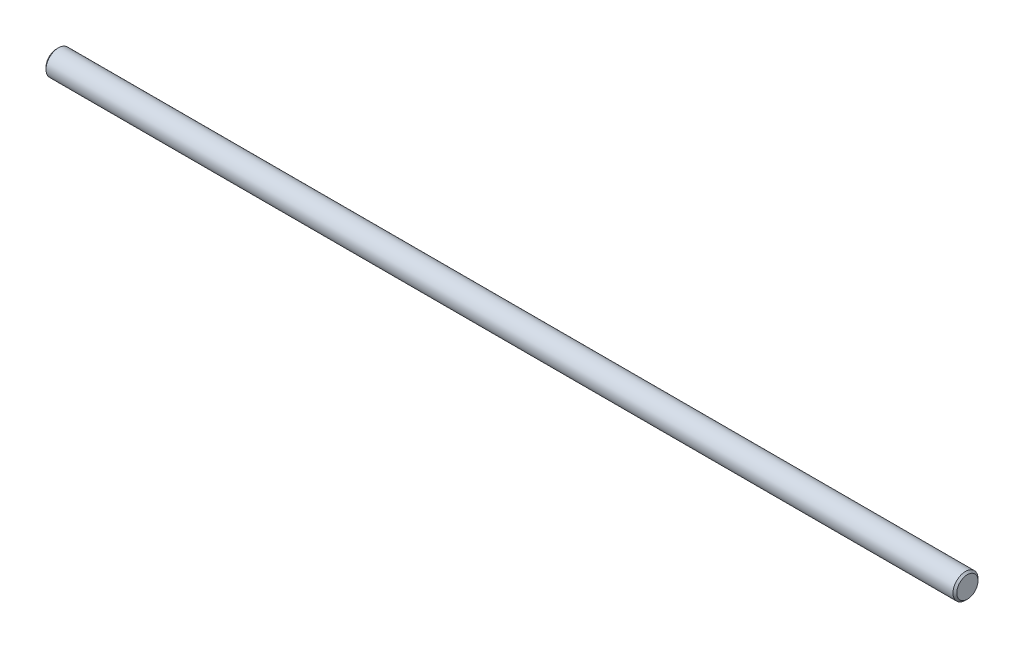
from build123d import *

# Parameters (mm, degrees)
SKETCH2_R                = 3.96875
BOSS_EXTRUDE1_DEPTH      = 144.4625
BOSS_EXTRUDE1_DEPTH_BACK = 144.4625
CHAMFER1_SIZE            = 0.5953125


with BuildPart() as part:
    # Sketch2 → Boss-Extrude1 (new body, two sides)
    with BuildSketch(Plane(origin=(0, 0, 0), x_dir=(0, 0, -1), z_dir=(1, 0, 0))) as boss_extrude1_sk:
        Circle(SKETCH2_R)
    extrude(amount=BOSS_EXTRUDE1_DEPTH)
    extrude(boss_extrude1_sk.sketch, amount=-BOSS_EXTRUDE1_DEPTH_BACK)

    # Chamfer1
    chamfer1_edges = [part.edges().sort_by_distance(p)[0] for p in [
        (-144.4625, 0, 3.96875),
        (144.4625, 0, 3.96875),
    ]]
    chamfer(chamfer1_edges, length=CHAMFER1_SIZE)


solid = part.part
